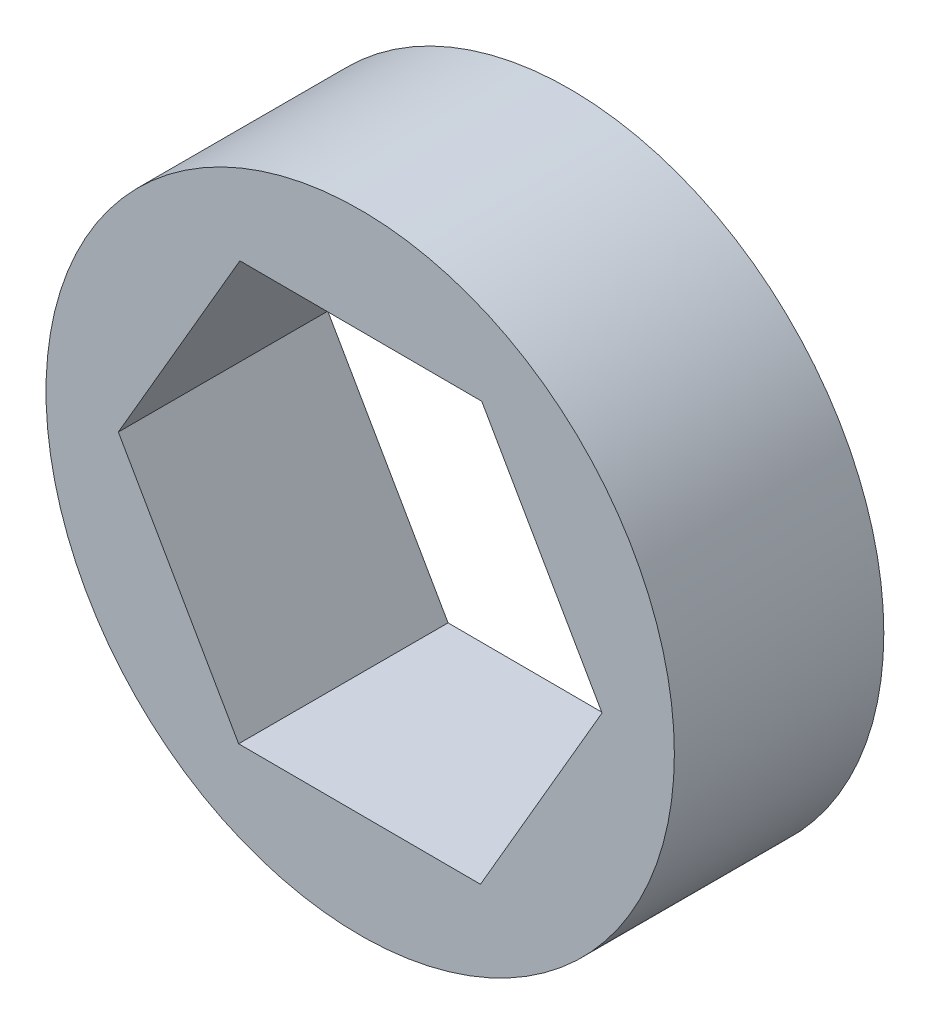
from build123d import *

# Parameters (mm, degrees)
SKETCH1_R           = 9.525
BOSS_EXTRUDE1_DEPTH = 6.35


with BuildPart() as part:
    # Sketch1 → Boss-Extrude1 (new body)
    with BuildSketch(Plane.XY):
        Circle(SKETCH1_R)
        Polygon((3.64699361, -6.361035367), (7.332315027, -0.022128569), (3.685321417, 6.338906797), (-3.64699361, 6.361035367), (-7.332315027, 0.022128569), (-3.685321417, -6.338906797), align=None, mode=Mode.SUBTRACT)
    extrude(amount=BOSS_EXTRUDE1_DEPTH)


solid = part.part
